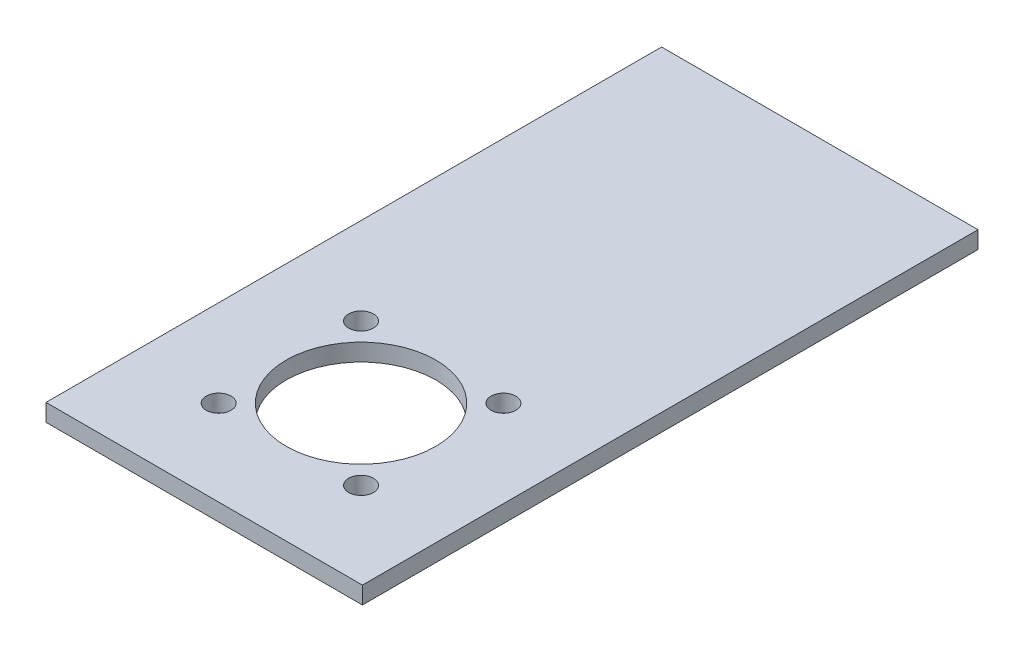
from build123d import *

# Parameters (mm, degrees)
SKETCH1_W           = 55
SKETCH1_H           = 107
SKETCH1_R           = 13
SKETCH1_R_2         = 2.15
BOSS_EXTRUDE1_DEPTH = 3


with BuildPart() as part:
    # Sketch1 → Boss-Extrude1 (new body)
    with BuildSketch(Plane(origin=(0, 0, 0), x_dir=(1, 0, 0), z_dir=(0, 1, 0))):
        with Locations((0, -7.358654807)):
            Rectangle(SKETCH1_W, SKETCH1_H)
        with Locations((0, -33.598654807)):
            Circle(SKETCH1_R, mode=Mode.SUBTRACT)
        with Locations((12.374368671, -21.224286136)):
            Circle(SKETCH1_R_2, mode=Mode.SUBTRACT)
        with Locations((12.374368671, -45.973023478)):
            Circle(SKETCH1_R_2, mode=Mode.SUBTRACT)
        with Locations((-12.374368671, -45.973023478)):
            Circle(SKETCH1_R_2, mode=Mode.SUBTRACT)
        with Locations((-12.374368671, -21.224286136)):
            Circle(SKETCH1_R_2, mode=Mode.SUBTRACT)
    extrude(amount=BOSS_EXTRUDE1_DEPTH)


solid = part.part
